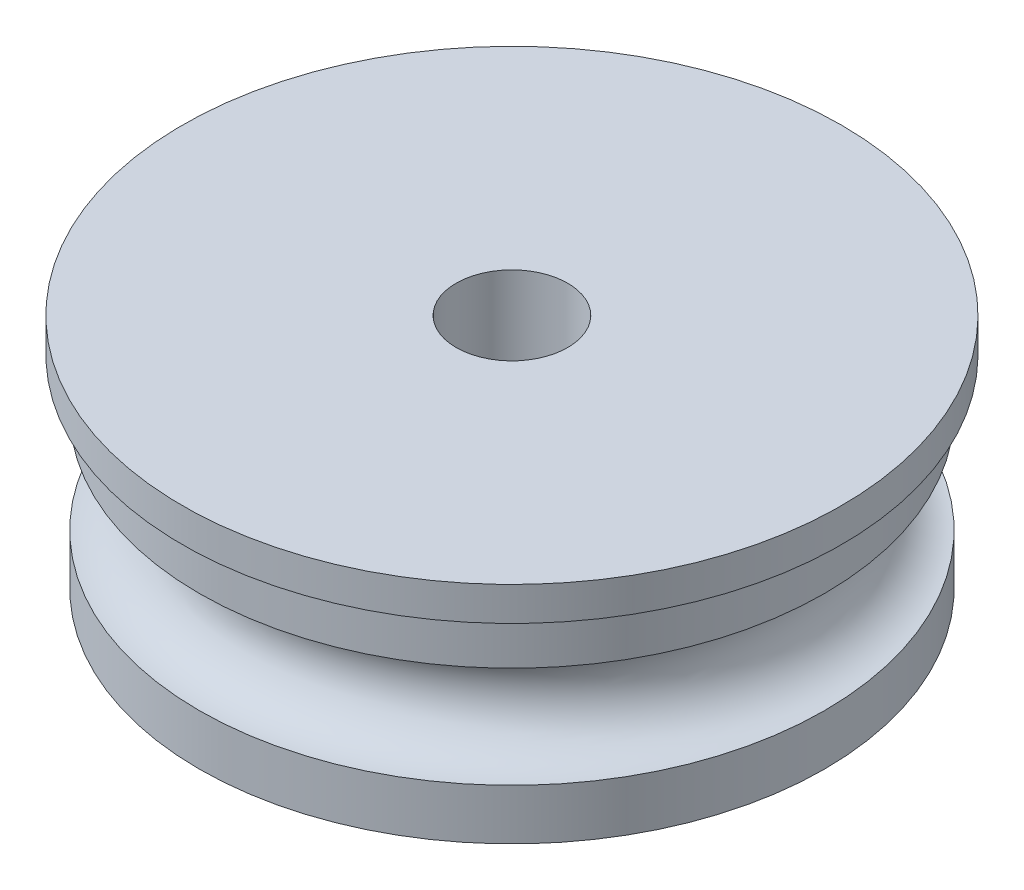
from build123d import *

# Parameters (mm, degrees)
SKETCH4_R                 = 6
CUT_EXTRUDE1_DEPTH        = 3
M4X0_7_TAPPED_HOLE1_D     = 3.3
M4X0_7_TAPPED_HOLE1_DEPTH = 4
M4X0_7_TAPPED_HOLE1_TIP   = 0.991420021


with BuildPart() as part:
    # Sketch1 → Revolve1 (revolve)
    with BuildSketch(Plane.XY):
        with BuildLine():
            Line((0, 0), (-9.25, 0))
            Line((-9.25, 0), (-9.25, 1.5))
            ThreePointArc((-9.25, 1.5), (-7.75, 3), (-9.25, 4.5))
            Line((-9.25, 4.5), (-9.25, 6))
            Line((-9.25, 6), (-9.75, 6))
            Line((-9.75, 6), (-9.75, 7))
            Line((-9.75, 7), (0, 7))
            Line((0, 7), (0, 0))
        make_face()
    revolve(axis=Axis((0, 0, 0), (0, 1, 0)))

    # Sketch4 → Cut-Extrude1 (cut)
    with BuildSketch(Plane.XZ):
        Circle(SKETCH4_R)
    extrude(amount=-CUT_EXTRUDE1_DEPTH, mode=Mode.SUBTRACT)

    # M4x0.7 Tapped Hole1
    with Locations(Plane(origin=(0, 7, 0), x_dir=(1, 0, 0), z_dir=(0, 1, 0))):
        with Locations((0, 0)):
            Hole(M4X0_7_TAPPED_HOLE1_D / 2, depth=M4X0_7_TAPPED_HOLE1_DEPTH)
            with Locations((0, 0, -(M4X0_7_TAPPED_HOLE1_DEPTH + M4X0_7_TAPPED_HOLE1_TIP / 2))):  # 118° drill point
                Cone(0, M4X0_7_TAPPED_HOLE1_D / 2, M4X0_7_TAPPED_HOLE1_TIP, mode=Mode.SUBTRACT)


solid = part.part
